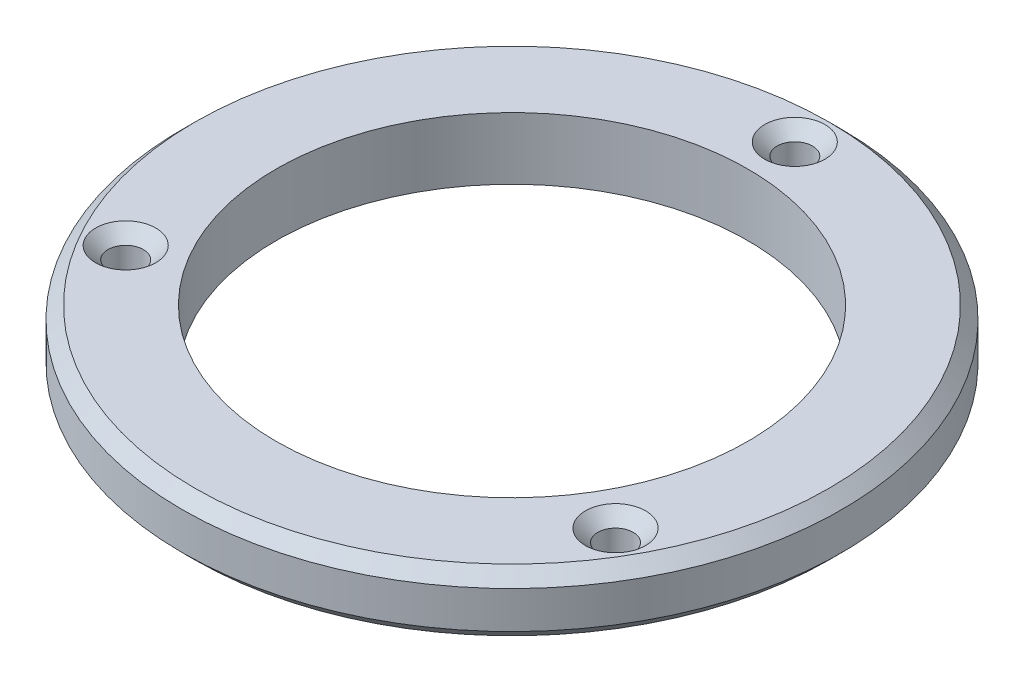
from build123d import *

# Parameters (mm, degrees)
SKETCH1_R           = 26.543
SKETCH1_R_2         = 19
SKETCH1_R_3         = 1.425
BOSS_EXTRUDE1_DEPTH = 5
CHAMFER1_SIZE       = 1
CHAMFER2_SIZE       = 1
CHAMFER3_SIZE       = 1
CHAMFER4_SIZE       = 1
CHAMFER5_SIZE       = 1


with BuildPart() as part:
    # Sketch1 → Boss-Extrude1 (new body)
    with BuildSketch(Plane(origin=(0, 0, 0), x_dir=(1, 0, 0), z_dir=(0, 1, 0))):
        Circle(SKETCH1_R)
        Circle(SKETCH1_R_2, mode=Mode.SUBTRACT)
        with Locations((0, 22.776724903)):
            Circle(SKETCH1_R_3, mode=Mode.SUBTRACT)
        with Locations((19.725222381, -11.388362451)):
            Circle(SKETCH1_R_3, mode=Mode.SUBTRACT)
        with Locations((-19.725222381, -11.388362451)):
            Circle(SKETCH1_R_3, mode=Mode.SUBTRACT)
    extrude(amount=BOSS_EXTRUDE1_DEPTH)

    # Chamfer1
    chamfer1_edges = [part.edges().sort_by_distance(p)[0] for p in [
        (-1.425, 5, -22.776724903),
    ]]
    chamfer(chamfer1_edges, length=CHAMFER1_SIZE)

    # Chamfer2
    chamfer2_edges = [part.edges().sort_by_distance(p)[0] for p in [
        (-21.150222381, 5, 11.388362451),
    ]]
    chamfer(chamfer2_edges, length=CHAMFER2_SIZE)

    # Chamfer3
    chamfer3_edges = [part.edges().sort_by_distance(p)[0] for p in [
        (18.300222381, 5, 11.388362451),
    ]]
    chamfer(chamfer3_edges, length=CHAMFER3_SIZE)

    # Chamfer4
    chamfer4_edges = [part.edges().sort_by_distance(p)[0] for p in [
        (-26.543, 5, 0),
    ]]
    chamfer(chamfer4_edges, length=CHAMFER4_SIZE)

    # Chamfer5
    chamfer5_edges = [part.edges().sort_by_distance(p)[0] for p in [
        (-26.543, 0, 0),
    ]]
    chamfer(chamfer5_edges, length=CHAMFER5_SIZE)


solid = part.part
